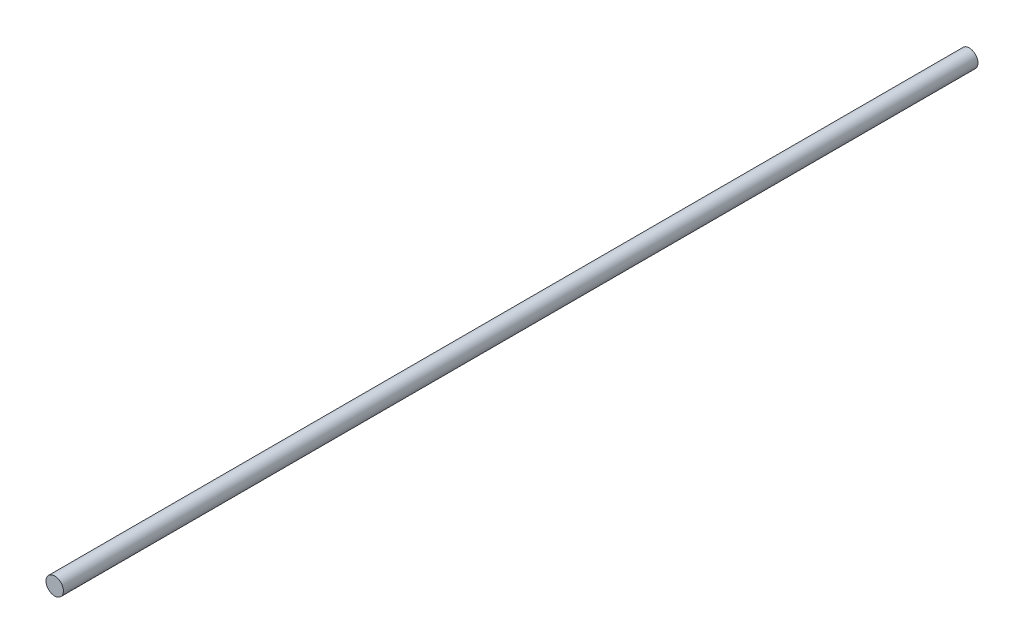
from build123d import *

# Parameters (mm, degrees)
ESBO_O1_R                = 4
RESSALTO_EXTRUS_O1_DEPTH = 420


with BuildPart() as part:
    # Esboço1 → Ressalto-extrusão1 (new body)
    with BuildSketch(Plane.XY):
        with Locations((-48.875298619, 81.407156415)):
            Circle(ESBO_O1_R)
    extrude(amount=RESSALTO_EXTRUS_O1_DEPTH)


solid = part.part
